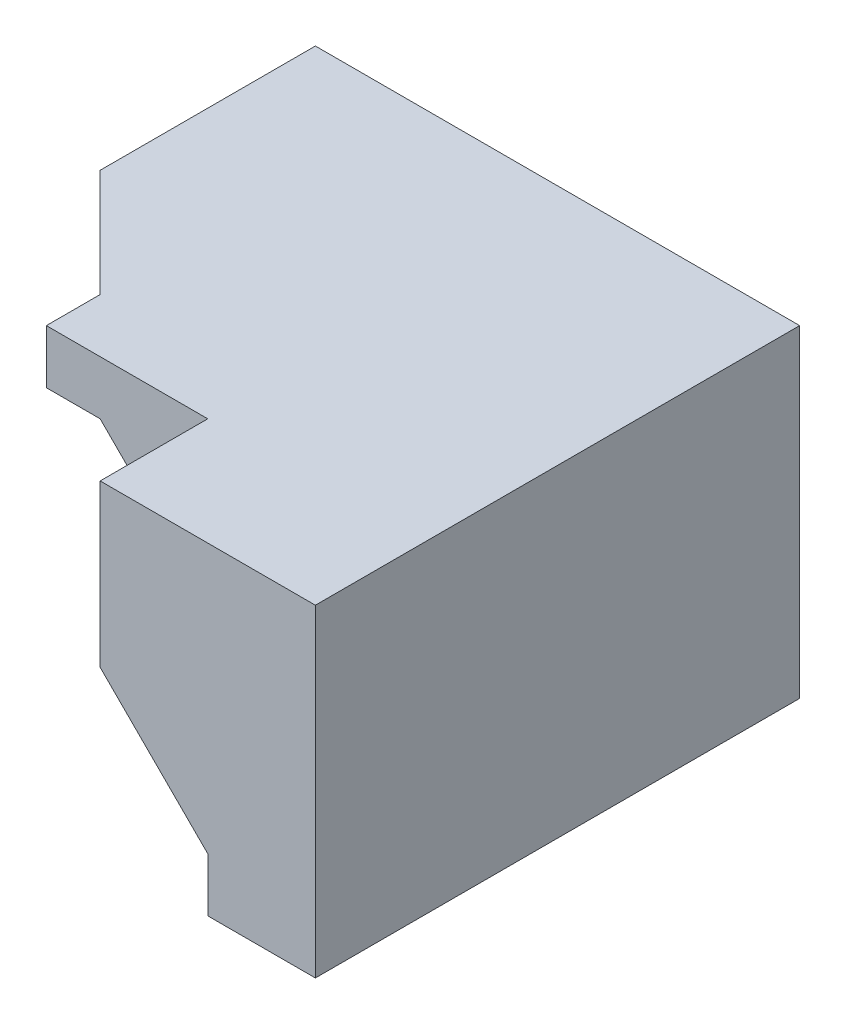
from build123d import *

# Parameters (mm, degrees)
BOSS_EXTRUDE1_DEPTH  = 90
BOSS_EXTRUDE2_DEPTH  = 70
BOSS_EXTRUDE4_DEPTH  = 10
SKETCH4_W            = 20
SKETCH4_H            = 40
BOSS_EXTRUDE6_DEPTH  = 20
CUT_EXTRUDE1_DEPTH   = 20
SKETCH9_W            = 20
SKETCH9_H            = 20
BOSS_EXTRUDE8_DEPTH  = 10
SKETCH10_W           = 20
SKETCH10_H           = 10
CUT_EXTRUDE2_DEPTH   = 10
BOSS_EXTRUDE9_START  = -10
BOSS_EXTRUDE9_DEPTH  = 20
SKETCH13_W           = 26.1880454
SKETCH13_H           = 20
BOSS_EXTRUDE13_DEPTH = 30
CUT_EXTRUDE3_DEPTH   = 10
BOSS_EXTRUDE14_DEPTH = 30
BOSS_EXTRUDE15_DEPTH = 30
BOSS_EXTRUDE16_DEPTH = 40
BOSS_EXTRUDE17_DEPTH = 40
BOSS_EXTRUDE18_DEPTH = 10


with BuildPart() as part:
    # Sketch1 → Boss-Extrude1 (new body)
    with BuildSketch(Plane.XY):
        Polygon((0, 0), (0, 30), (40, 30), (40, -30), (20, -30), (20, -20), align=None)
    extrude(amount=BOSS_EXTRUDE1_DEPTH)

    # Sketch2 → Boss-Extrude2 (add)
    with BuildSketch(Plane.XY.offset(70)):
        Polygon((0, 30), (-30, 30), (-30, 20), (-20, 20), (0, 0), align=None)
    extrude(amount=-BOSS_EXTRUDE2_DEPTH)

    # Sketch3 → Boss-Extrude4 (add)
    with BuildSketch(Plane(origin=(0, 30, 0), x_dir=(1, 0, 0), z_dir=(0, 1, 0))):
        Polygon((-30, -60), (-50, -40), (-30, -40), align=None)
    extrude(amount=-BOSS_EXTRUDE4_DEPTH)

    # Sketch4 → Boss-Extrude6 (add)
    with BuildSketch(Plane(origin=(0, 30, 0), x_dir=(1, 0, 0), z_dir=(0, 1, 0))):
        with Locations((-40, -20)):
            Rectangle(SKETCH4_W, SKETCH4_H)
    extrude(amount=-BOSS_EXTRUDE6_DEPTH)

    # Sketch6 → Cut-Extrude1 (cut)
    with BuildSketch(Plane.ZY.offset(50)):
        Polygon((40, 20), (30, 10), (40, 10), align=None)
    extrude(amount=-CUT_EXTRUDE1_DEPTH, mode=Mode.SUBTRACT)

    # Sketch9 → Boss-Extrude8 (add)
    with BuildSketch(Plane.XZ.offset(-10)):
        with Locations((-40, 10)):
            Rectangle(SKETCH9_W, SKETCH9_H)
    extrude(amount=BOSS_EXTRUDE8_DEPTH)

    # Sketch10 → Cut-Extrude2 (cut)
    with BuildSketch(Plane.ZY.offset(50)):
        with Locations((10, 5)):
            Rectangle(SKETCH10_W, SKETCH10_H)
    extrude(amount=-CUT_EXTRUDE2_DEPTH, mode=Mode.SUBTRACT)

    # Sketch11 → Boss-Extrude9 (add)
    with BuildSketch(Plane(origin=(-30, 0, 0), x_dir=(0, 0, -1), z_dir=(1, 0, 0)).offset(BOSS_EXTRUDE9_START)):
        Polygon((-20, 0), (-30, 10), (-20, 10), align=None)
    extrude(amount=BOSS_EXTRUDE9_DEPTH)

    # Sketch13 → Boss-Extrude13 (add)
    with BuildSketch(Plane(origin=(0, 0, 0), x_dir=(-1, 0, 0), z_dir=(0, 0, -1))):
        with Locations((16.9059773, 10)):
            Rectangle(SKETCH13_W, SKETCH13_H)
    extrude(amount=-BOSS_EXTRUDE13_DEPTH)

    # Sketch14 → Cut-Extrude3 (cut)
    with BuildSketch(Plane.ZY.offset(30)):
        Polygon((20, 0), (30, 10), (30, 0), align=None)
    extrude(amount=-CUT_EXTRUDE3_DEPTH, mode=Mode.SUBTRACT)

    # Sketch15 → Boss-Extrude14 (add)
    with BuildSketch(Plane.ZY.offset(50)):
        Polygon((30, 10), (30, 20), (40, 20), align=None)
    extrude(amount=-BOSS_EXTRUDE14_DEPTH)

    # Sketch16 → Boss-Extrude15 (add)
    with BuildSketch(Plane.XZ.offset(30)):
        Polygon((20, 0), (10, 0), (10, 40), (20, 60), align=None)
    extrude(amount=-BOSS_EXTRUDE15_DEPTH)

    # Sketch17 → Boss-Extrude16 (add)
    with BuildSketch(Plane(origin=(0, 0, 0), x_dir=(-1, 0, 0), z_dir=(0, 0, -1))):
        Polygon((-10, -30), (20, -10), (20, 0), (0, 0), (-10, -10), align=None)
    extrude(amount=-BOSS_EXTRUDE16_DEPTH)

    # Sketch18 → Boss-Extrude17 (add)
    with BuildSketch(Plane(origin=(0, 0, 0), x_dir=(-1, 0, 0), z_dir=(0, 0, -1))):
        Polygon((3.8119546, 3.8119546), (3.8119546, 0), (0, 0), align=None)
    extrude(amount=-BOSS_EXTRUDE17_DEPTH)

    # Sketch19 → Boss-Extrude18 (add)
    with BuildSketch(Plane.XY.offset(30)):
        Polygon((-3.8119546, 3.8119546), (-3.8119546, 0), (-20, 0), (-20, 20), align=None)
    extrude(amount=BOSS_EXTRUDE18_DEPTH)


solid = part.part
